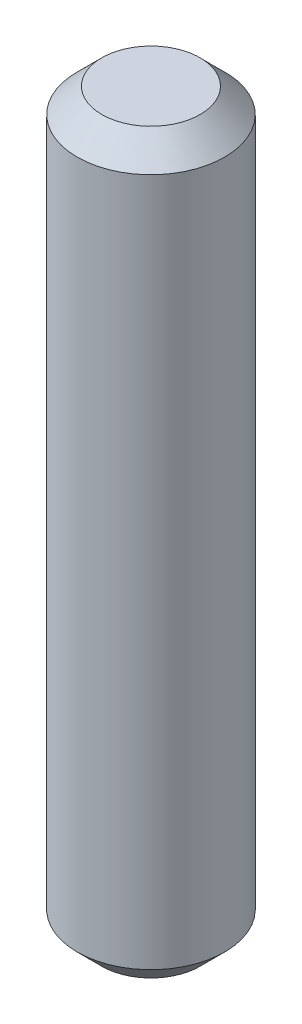
from build123d import *

# Parameters (mm, degrees)
SKETCH1_R           = 3
BOSS_EXTRUDE1_DEPTH = 30
CHAMFER1_SIZE       = 1


with BuildPart() as part:
    # Sketch1 → Boss-Extrude1 (new body)
    with BuildSketch(Plane(origin=(0, 0, 0), x_dir=(1, 0, 0), z_dir=(0, 1, 0))):
        Circle(SKETCH1_R)
    extrude(amount=BOSS_EXTRUDE1_DEPTH)

    # Chamfer1
    chamfer1_edges = [part.edges().sort_by_distance(p)[0] for p in [
        (-3, 0, 0),
        (-3, 30, 0),
    ]]
    chamfer(chamfer1_edges, length=CHAMFER1_SIZE)


solid = part.part
